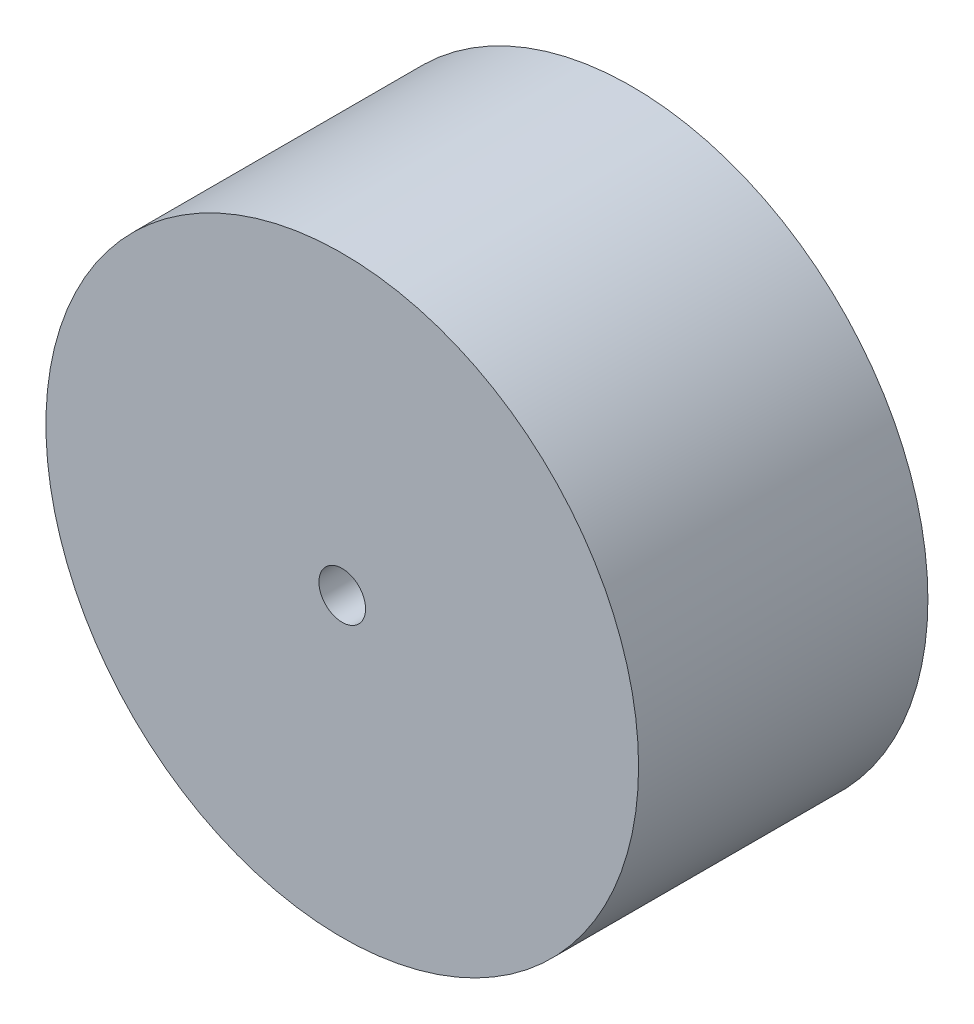
from build123d import *

# Parameters (mm, degrees)
SKETCH1_R           = 63.5
BOSS_EXTRUDE1_DEPTH = 62
SKETCH2_R           = 5
CUT_EXTRUDE1_DEPTH  = 63


with BuildPart() as part:
    # Sketch1 → Boss-Extrude1 (new body)
    with BuildSketch(Plane.XY):
        Circle(SKETCH1_R)
    extrude(amount=BOSS_EXTRUDE1_DEPTH)

    # Sketch2 → Cut-Extrude1 (cut, through all)
    with BuildSketch(Plane(origin=(0, 0, 0), x_dir=(-1, 0, 0), z_dir=(0, 0, -1))):
        Circle(SKETCH2_R)
    extrude(amount=-CUT_EXTRUDE1_DEPTH, mode=Mode.SUBTRACT)


solid = part.part
